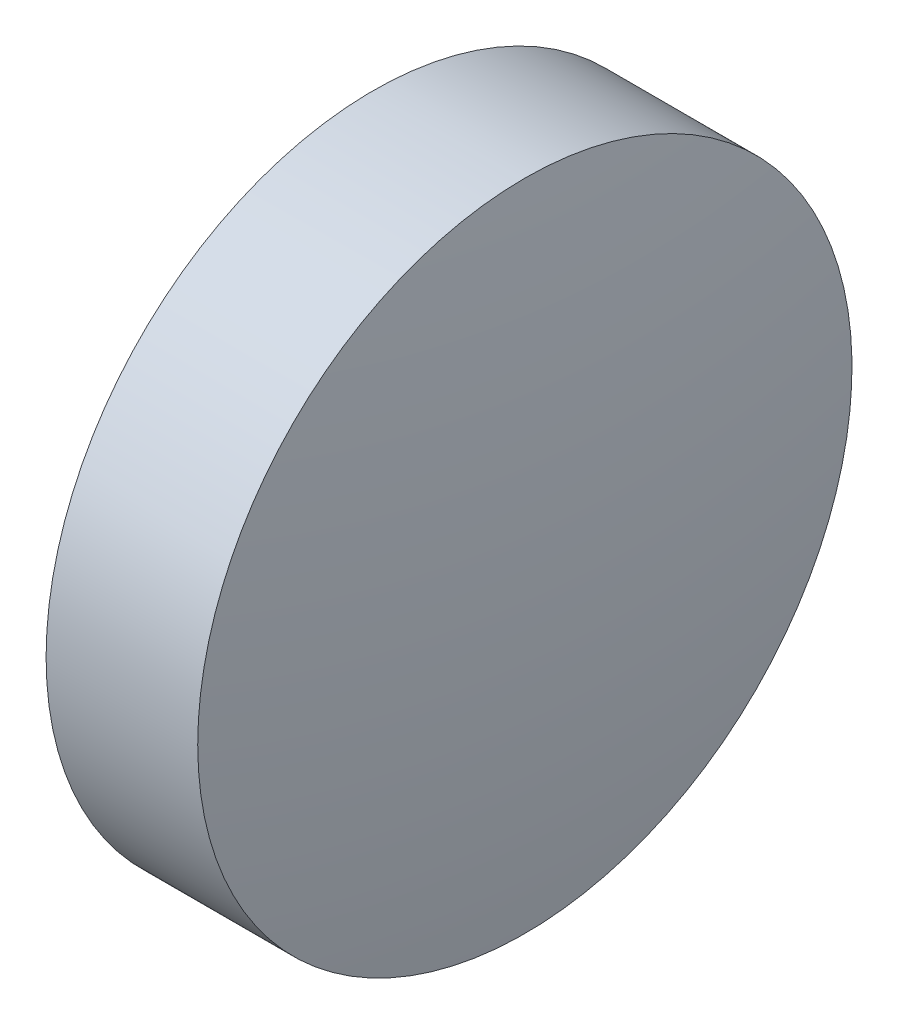
from build123d import *


with BuildPart() as part:
    # 草图1 → 旋转1 (revolve)
    with BuildSketch(Plane.XY):
        with BuildLine():
            Line((818.462867468, 336.559230444), (818.462867468, 339.709230444))
            Line((818.462867468, 339.709230444), (819.922867468, 339.709230444))
            ThreePointArc((819.922867468, 339.709230444), (820.102780645, 338.138795257), (820.162867468, 336.559230444))
            Line((820.162867468, 336.559230444), (818.462867468, 336.559230444))
        make_face()
    revolve(axis=Axis((798.266287632, 336.559230444, 0), (1, 0, 0)))


solid = part.part
